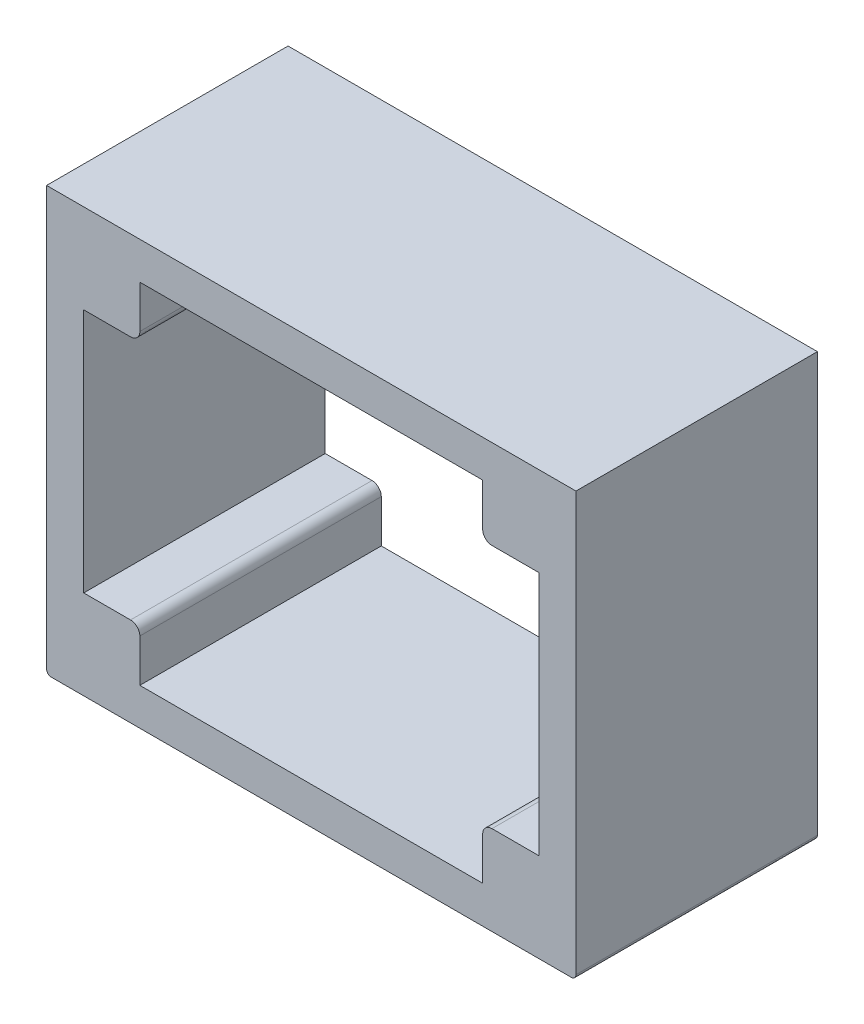
from build123d import *

# Parameters (mm, degrees)
BOSS_EXTRUDE1_DEPTH = 82.55


with BuildPart() as part:
    # Sketch1 → Boss-Extrude1 (new body)
    with BuildSketch(Plane.XY):
        with BuildLine():
            Line((174.498, 0), (-6.477, 0))
            Line((-6.477, 0), (-6.477, -143.1925))
            ThreePointArc((-6.477, -143.1925), (-6.012032015, -144.315032015), (-4.8895, -144.78))
            Line((-4.8895, -144.78), (172.9105, -144.78))
            ThreePointArc((172.9105, -144.78), (174.033032015, -144.315032015), (174.498, -143.1925))
            Line((174.498, -143.1925), (174.498, 0))
        make_face()
        with BuildLine():
            Line((6.223, -114.3), (22.225, -114.3))
            ThreePointArc((22.225, -114.3), (24.47006403, -115.22993597), (25.4, -117.475))
            Line((25.4, -117.475), (25.4, -132.08))
            Line((25.4, -132.08), (142.621, -132.08))
            Line((142.621, -132.08), (142.621, -117.475))
            ThreePointArc((142.621, -117.475), (143.55093597, -115.22993597), (145.796, -114.3))
            Line((145.796, -114.3), (161.798, -114.3))
            Line((161.798, -114.3), (161.798, -30.48))
            Line((161.798, -30.48), (145.796, -30.48))
            ThreePointArc((145.796, -30.48), (143.55093597, -29.55006403), (142.621, -27.305))
            Line((142.621, -27.305), (142.621, -12.7))
            Line((142.621, -12.7), (25.4, -12.7))
            Line((25.4, -12.7), (25.4, -27.305))
            ThreePointArc((25.4, -27.305), (24.47006403, -29.55006403), (22.225, -30.48))
            Line((22.225, -30.48), (6.223, -30.48))
            Line((6.223, -30.48), (6.223, -114.3))
        make_face(mode=Mode.SUBTRACT)
    extrude(amount=BOSS_EXTRUDE1_DEPTH)


solid = part.part
